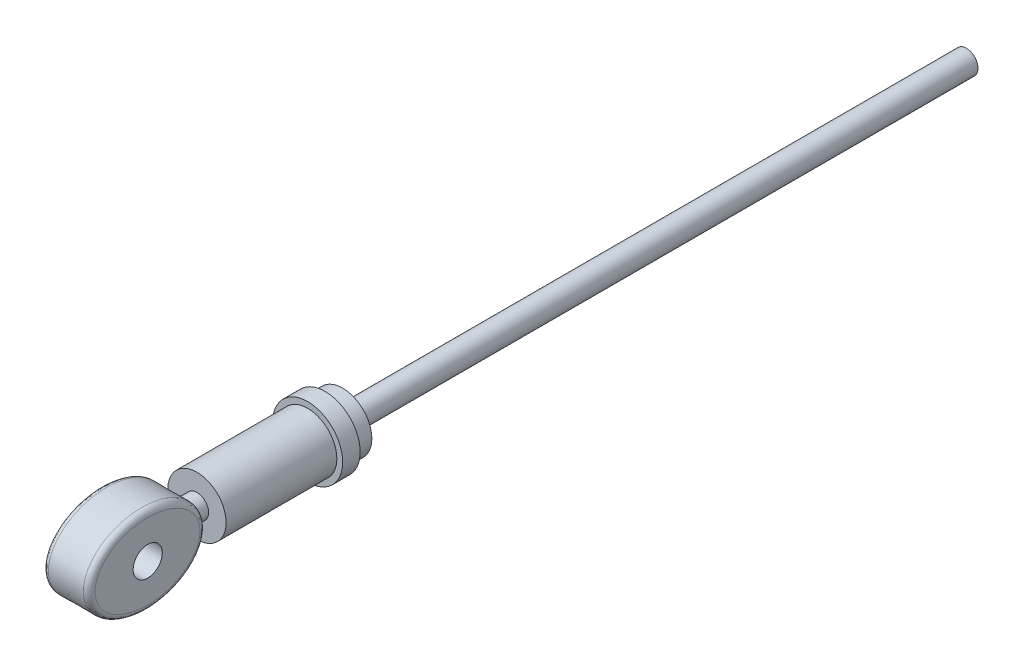
from build123d import *

# Parameters (mm, degrees)
SKETCH1_R           = 5
BOSS_EXTRUDE1_DEPTH = 19
SKETCH2_R           = 6
BOSS_EXTRUDE2_DEPTH = 3
SKETCH3_R           = 5
BOSS_EXTRUDE3_DEPTH = 3
SKETCH4_R           = 2
BOSS_EXTRUDE4_DEPTH = 107
SKETCH5_RX          = 10
SKETCH5_RY          = 7.5
BOSS_EXTRUDE5_DEPTH = 4
SKETCH6_R           = 2
BOSS_EXTRUDE6_DEPTH = 4
FILLET1_R           = 1
SKETCH7_R           = 2.5
CUT_EXTRUDE1_DEPTH  = 11


with BuildPart() as part:
    # Sketch1 → Boss-Extrude1 (new body)
    with BuildSketch(Plane.XY):
        Circle(SKETCH1_R)
    extrude(amount=BOSS_EXTRUDE1_DEPTH)

    # Sketch2 → Boss-Extrude2 (add)
    with BuildSketch(Plane(origin=(0, 0, 0), x_dir=(-1, 0, 0), z_dir=(0, 0, -1))):
        Circle(SKETCH2_R)
    extrude(amount=BOSS_EXTRUDE2_DEPTH)

    # Sketch3 → Boss-Extrude3 (add)
    with BuildSketch(Plane(origin=(0, 0, -3), x_dir=(-1, 0, 0), z_dir=(0, 0, -1))):
        Circle(SKETCH3_R)
    extrude(amount=BOSS_EXTRUDE3_DEPTH)

    # Sketch4 → Boss-Extrude4 (add)
    with BuildSketch(Plane(origin=(0, 0, -6), x_dir=(-1, 0, 0), z_dir=(0, 0, -1))):
        Circle(SKETCH4_R)
    extrude(amount=BOSS_EXTRUDE4_DEPTH)



with BuildPart() as body_2:
    # Sketch5 → Boss-Extrude5 (new body, symmetric)
    with BuildSketch(Plane(origin=(0, 0, 0), x_dir=(0, 0, -1), z_dir=(1, 0, 0))):
        with Locations(Location((-31.48355656, 0), (0, 0, 180))):
            Ellipse(SKETCH5_RX, SKETCH5_RY)
    extrude(amount=BOSS_EXTRUDE5_DEPTH, both=True)


with BuildPart() as part_1:
    add(part.part)

    add(body_2.part)  # Boss-Extrude6 merges body 2
    # Sketch6 → Boss-Extrude6 (add)
    with BuildSketch(Plane.XY.offset(19)):
        Circle(SKETCH6_R)
    extrude(amount=BOSS_EXTRUDE6_DEPTH)

    # Fillet1
    fillet1_edges = [part_1.edges().sort_by_distance(p)[0] for p in [
        (-4, 0.002625288, 21.483557173),
        (4, 0.002625288, 21.483557173),
    ]]
    fillet(fillet1_edges, radius=FILLET1_R)

    # Sketch7 → Cut-Extrude1 (cut, through all)
    with BuildSketch(Plane(origin=(4, 0, 0), x_dir=(0, 0, -1), z_dir=(1, 0, 0))):
        with Locations((-31.444890306, 0)):
            Circle(SKETCH7_R)
    extrude(amount=-CUT_EXTRUDE1_DEPTH, mode=Mode.SUBTRACT)


solid = part_1.part
